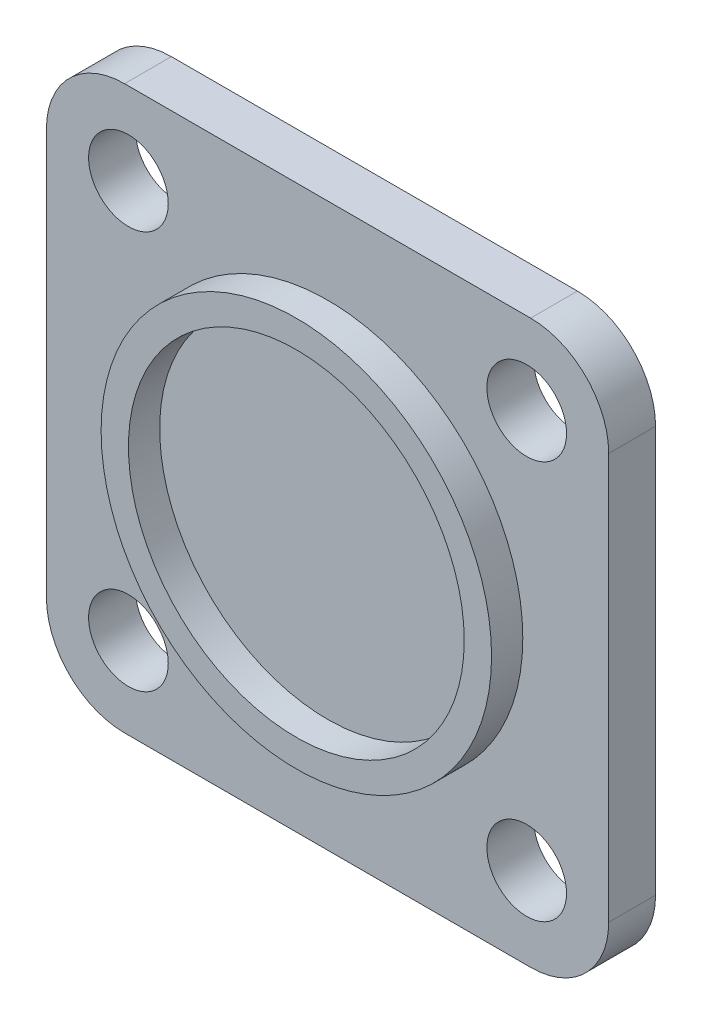
from build123d import *

# Parameters (mm, degrees)
SZKIC1_R                     = 2.55
DODANIE_WYCI_GNI_CIE11_DEPTH = 3
SZKIC7_R                     = 12.5
SZKIC7_R_2                   = 10.75
DODANIE_WYCI_GNI_CIE12_DEPTH = 2


with BuildPart() as part:
    # Szkic1 → Dodanie-wyciągnięcie11 (new body)
    with BuildSketch(Plane.XY):
        with BuildLine():
            Line((-3.026929241, 2.183576975), (22.973070759, 2.183576975))
            ThreePointArc((22.973070759, 2.183576975), (26.508604665, 0.719110881), (27.973070759, -2.816423025))
            Line((27.973070759, -2.816423025), (27.973070759, -28.816423025))
            ThreePointArc((27.973070759, -28.816423025), (26.508604665, -32.351956931), (22.973070759, -33.816423025))
            Line((22.973070759, -33.816423025), (-3.026929241, -33.816423025))
            ThreePointArc((-3.026929241, -33.816423025), (-6.562463147, -32.351956931), (-8.026929241, -28.816423025))
            Line((-8.026929241, -28.816423025), (-8.026929241, -2.816423025))
            ThreePointArc((-8.026929241, -2.816423025), (-6.562463147, 0.719110881), (-3.026929241, 2.183576975))
        make_face()
        with Locations((-2.776929241, -3.066423025)):
            Circle(SZKIC1_R, mode=Mode.SUBTRACT)
        with Locations((22.723070759, -3.066423025)):
            Circle(SZKIC1_R, mode=Mode.SUBTRACT)
        with Locations((-2.776929241, -28.566423025)):
            Circle(SZKIC1_R, mode=Mode.SUBTRACT)
        with Locations((22.723070759, -28.566423025)):
            Circle(SZKIC1_R, mode=Mode.SUBTRACT)
    extrude(amount=DODANIE_WYCI_GNI_CIE11_DEPTH)

    # Szkic7 → Dodanie-wyciągnięcie12 (add)
    with BuildSketch(Plane.XY.offset(3)):
        with Locations((9.973070759, -15.816423025)):
            Circle(SZKIC7_R)
        with Locations((9.973070759, -15.816423025)):
            Circle(SZKIC7_R_2, mode=Mode.SUBTRACT)
    extrude(amount=DODANIE_WYCI_GNI_CIE12_DEPTH)


solid = part.part
